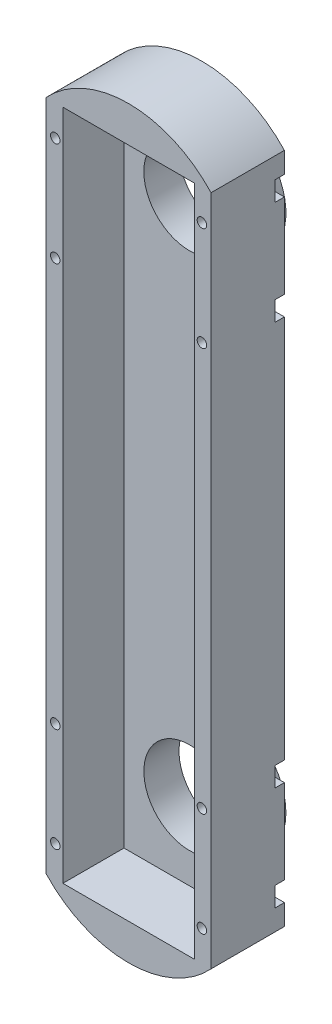
from build123d import *

# Parameters (mm, degrees)
SKETCH_1_W          = 54
SKETCH_1_H          = 220
EXTRUDE_1_DEPTH     = 24
SKETCH_2_R          = 1.55
CUT_EXTRUDE_1_DEPTH = 25
EXTRUDE_2_DEPTH     = 24
SKETCH_5_W          = 43
SKETCH_5_H          = 220
CUT_EXTRUDE_3_DEPTH = 20
CUT_EXTRUDE_4_DEPTH = 3
SKETCH_7_R          = 15
CUT_EXTRUDE_5_DEPTH = 25
SKETCH_11_R         = 20
SKETCH_11_R_2       = 15
EXTRUDE_3_DEPTH     = 7.5
SKETCH_12_R         = 21
SKETCH_12_R_2       = 20
EXTRUDE_4_DEPTH     = 0.5


with BuildPart() as part:
    # 草图1 → 凸台-拉伸1 (new body)
    with BuildSketch(Plane.XY):
        Rectangle(SKETCH_1_W, SKETCH_1_H)
    extrude(amount=EXTRUDE_1_DEPTH)

    # 草图2 → 切除-拉伸1 (cut, through all)
    with BuildSketch(Plane.XY.offset(24)):
        with Locations((-24, 100)):
            Circle(SKETCH_2_R)
        with Locations((24, 100)):
            Circle(SKETCH_2_R)
        with Locations((24, 66)):
            Circle(SKETCH_2_R)
        with Locations((-24, 66)):
            Circle(SKETCH_2_R)
        with Locations((24, -100)):
            Circle(SKETCH_2_R)
        with Locations((24, -66)):
            Circle(SKETCH_2_R)
        with Locations((-24, -66)):
            Circle(SKETCH_2_R)
        with Locations((-24, -100)):
            Circle(SKETCH_2_R)
    extrude(amount=-CUT_EXTRUDE_1_DEPTH, mode=Mode.SUBTRACT)

    # 草图3 → 凸台-拉伸2 (add)
    with BuildSketch(Plane.XY.offset(24)):
        with BuildLine():
            Line((-27, 110), (27, 110))
            ThreePointArc((27, 110), (0, 121.795200461), (-27, 110))
        make_face()
        with BuildLine():
            Line((-27, -110), (27, -110))
            ThreePointArc((27, -110), (0, -121.795200461), (-27, -110))
        make_face()
    extrude(amount=-EXTRUDE_2_DEPTH)

    # 草图5 → 切除-拉伸3 (cut)
    with BuildSketch(Plane.XY.offset(24)):
        Rectangle(SKETCH_5_W, SKETCH_5_H)
    extrude(amount=-CUT_EXTRUDE_3_DEPTH, mode=Mode.SUBTRACT)

    # 草图6 → 切除-拉伸4 (cut)
    with BuildSketch(Plane(origin=(0, 0, 0), x_dir=(-1, 0, 0), z_dir=(0, 0, -1))):
        with BuildLine():
            Line((-27, 69.2), (-24, 69.2))
            ThreePointArc((-24, 69.2), (-20.8, 66), (-24, 62.8))
            Line((-24, 62.8), (-27, 62.8))
            Line((-27, 62.8), (-27, 69.2))
        make_face()
        with BuildLine():
            Line((-27, 103.2), (-27, 96.8))
            Line((-27, 96.8), (-24, 96.8))
            ThreePointArc((-24, 96.8), (-20.8, 100), (-24, 103.2))
            Line((-24, 103.2), (-27, 103.2))
        make_face()
        with BuildLine():
            Line((27, 69.2), (24, 69.2))
            ThreePointArc((24, 69.2), (20.8, 66), (24, 62.8))
            Line((24, 62.8), (27, 62.8))
            Line((27, 62.8), (27, 69.2))
        make_face()
        with BuildLine():
            Line((27, 103.2), (24, 103.2))
            ThreePointArc((24, 103.2), (20.8, 100), (24, 96.8))
            Line((24, 96.8), (27, 96.8))
            Line((27, 96.8), (27, 103.2))
        make_face()
        with BuildLine():
            Line((27, -69.2), (27, -62.8))
            Line((27, -62.8), (24, -62.8))
            ThreePointArc((24, -62.8), (20.8, -66), (24, -69.2))
            Line((24, -69.2), (27, -69.2))
        make_face()
        with BuildLine():
            Line((27, -103.2), (27, -96.8))
            Line((27, -96.8), (24, -96.8))
            ThreePointArc((24, -96.8), (20.8, -100), (24, -103.2))
            Line((24, -103.2), (27, -103.2))
        make_face()
        with BuildLine():
            Line((-27, -103.2), (-24, -103.2))
            ThreePointArc((-24, -103.2), (-20.8, -100), (-24, -96.8))
            Line((-24, -96.8), (-27, -96.8))
            Line((-27, -96.8), (-27, -103.2))
        make_face()
        with BuildLine():
            Line((-27, -69.2), (-24, -69.2))
            ThreePointArc((-24, -69.2), (-20.8, -66), (-24, -62.8))
            Line((-24, -62.8), (-27, -62.8))
            Line((-27, -62.8), (-27, -69.2))
        make_face()
    extrude(amount=-CUT_EXTRUDE_4_DEPTH, mode=Mode.SUBTRACT)

    # 草图7 → 切除-拉伸5 (cut, through all)
    with BuildSketch(Plane(origin=(0, 0, 0), x_dir=(-1, 0, 0), z_dir=(0, 0, -1))):
        with Locations((0, 85)):
            Circle(SKETCH_7_R)
        with Locations((0, -85)):
            Circle(SKETCH_7_R)
    extrude(amount=-CUT_EXTRUDE_5_DEPTH, mode=Mode.SUBTRACT)

    # 草图11 → 凸台-拉伸3 (add)
    with BuildSketch(Plane(origin=(0, 0, 0), x_dir=(-1, 0, 0), z_dir=(0, 0, -1))):
        with Locations((0, 85)):
            Circle(SKETCH_11_R)
        with Locations((0, 85)):
            Circle(SKETCH_11_R_2, mode=Mode.SUBTRACT)
        with Locations((0, -85)):
            Circle(SKETCH_11_R)
        with Locations((0, -85)):
            Circle(SKETCH_11_R_2, mode=Mode.SUBTRACT)
    extrude(amount=EXTRUDE_3_DEPTH)

    # 草图12 → 凸台-拉伸4 (add)
    with BuildSketch(Plane(origin=(0, 0, 0), x_dir=(-1, 0, 0), z_dir=(0, 0, -1))):
        with Locations((0, 85)):
            Circle(SKETCH_12_R)
        with Locations((0, 85)):
            Circle(SKETCH_12_R_2, mode=Mode.SUBTRACT)
        with Locations((0, -85)):
            Circle(SKETCH_12_R)
        with Locations((0, -85)):
            Circle(SKETCH_12_R_2, mode=Mode.SUBTRACT)
    extrude(amount=EXTRUDE_4_DEPTH)


solid = part.part
